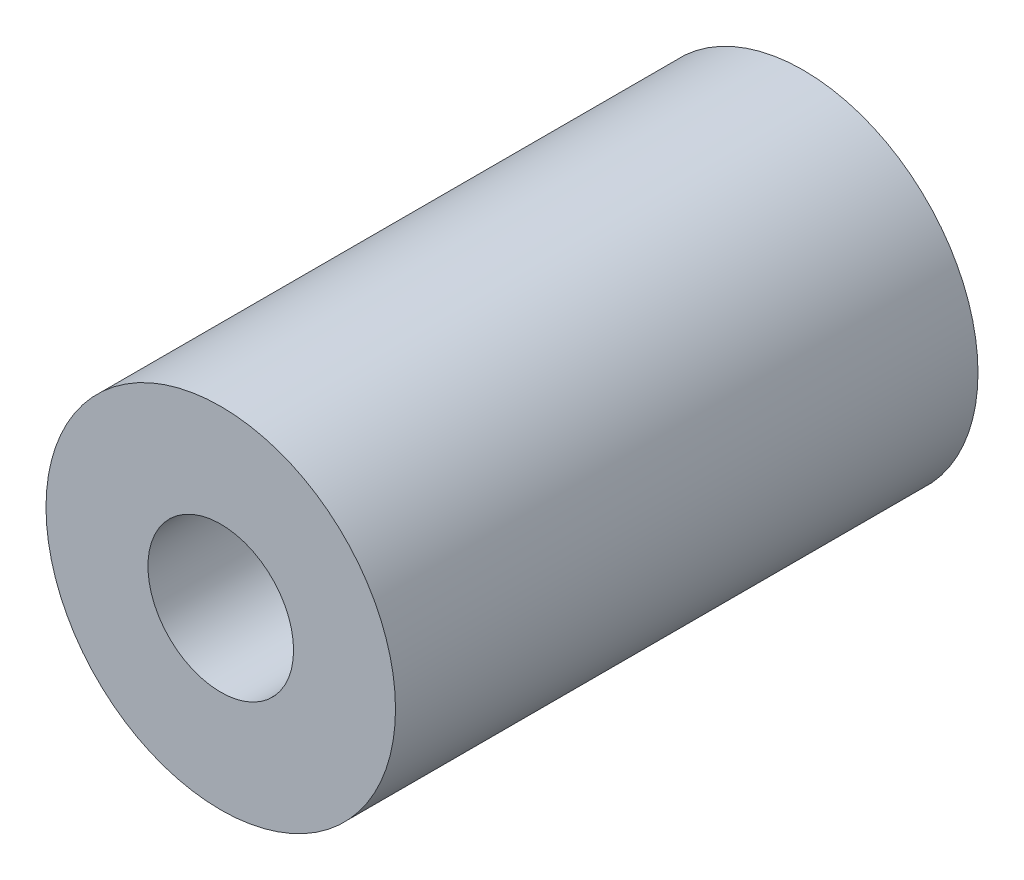
from build123d import *

# Parameters (mm, degrees)
SKETCH1_R             = 3
BOSS_EXTRUDE1_DEPTH   = 10
M3X0_5_TAPPED_HOLE1_D = 2.5


with BuildPart() as part:
    # Sketch1 → Boss-Extrude1 (new body)
    with BuildSketch(Plane.XY):
        Circle(SKETCH1_R)
    extrude(amount=BOSS_EXTRUDE1_DEPTH)

    # M3x0.5 Tapped Hole1 (through all)
    with Locations(Plane.XY.offset(10)):
        with Locations((0, 0)):
            Hole(M3X0_5_TAPPED_HOLE1_D / 2)


solid = part.part
